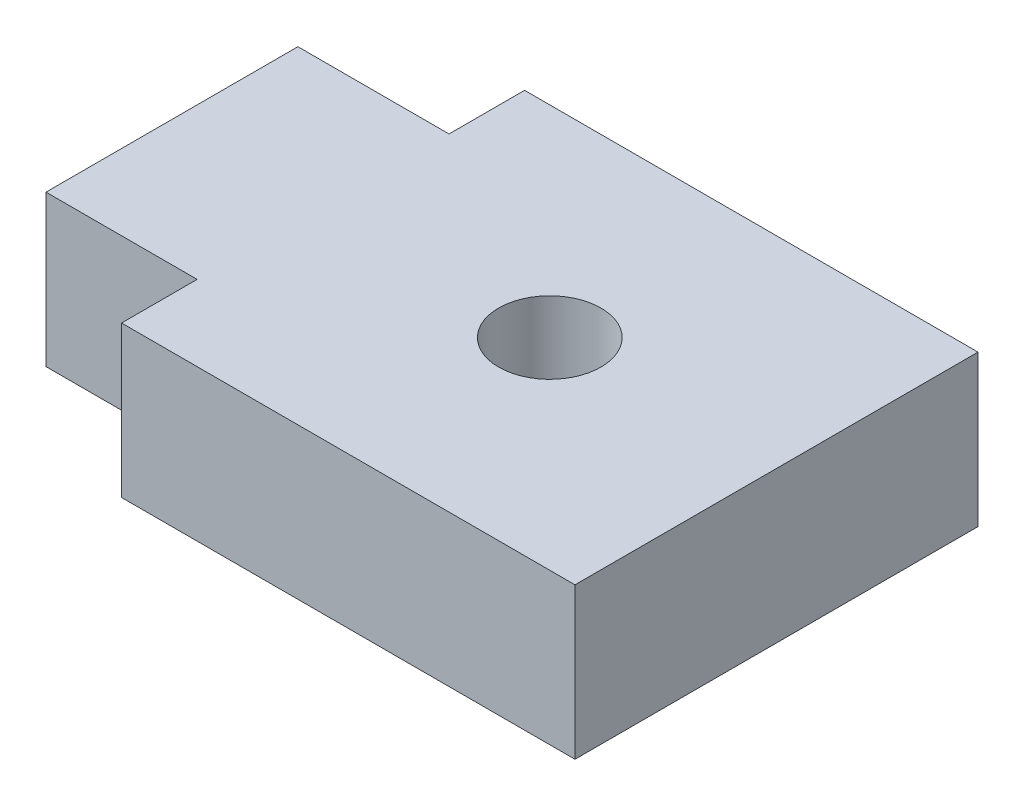
from build123d import *

# Parameters (mm, degrees)
SKETCH1_W           = 9
SKETCH1_H           = 8
BOSS_EXTRUDE1_DEPTH = 3
SKETCH2_W           = 3
SKETCH2_H           = 5
BOSS_EXTRUDE2_DEPTH = 3
SKETCH3_R           = 1.016
CUT_EXTRUDE1_DEPTH  = 4


with BuildPart() as part:
    # Sketch1 → Boss-Extrude1 (new body)
    with BuildSketch(Plane(origin=(0, 0, 0), x_dir=(1, 0, 0), z_dir=(0, 1, 0))):
        Rectangle(SKETCH1_W, SKETCH1_H)
    extrude(amount=BOSS_EXTRUDE1_DEPTH)

    # Sketch2 → Boss-Extrude2 (add)
    with BuildSketch(Plane(origin=(0, 3, 0), x_dir=(1, 0, 0), z_dir=(0, 1, 0))):
        with Locations((-6, 0)):
            Rectangle(SKETCH2_W, SKETCH2_H)
    extrude(amount=-BOSS_EXTRUDE2_DEPTH)

    # Sketch3 → Cut-Extrude1 (cut, through all)
    with BuildSketch(Plane(origin=(0, 3, 0), x_dir=(1, 0, 0), z_dir=(0, 1, 0))):
        Circle(SKETCH3_R)
    extrude(amount=-CUT_EXTRUDE1_DEPTH, mode=Mode.SUBTRACT)


solid = part.part
